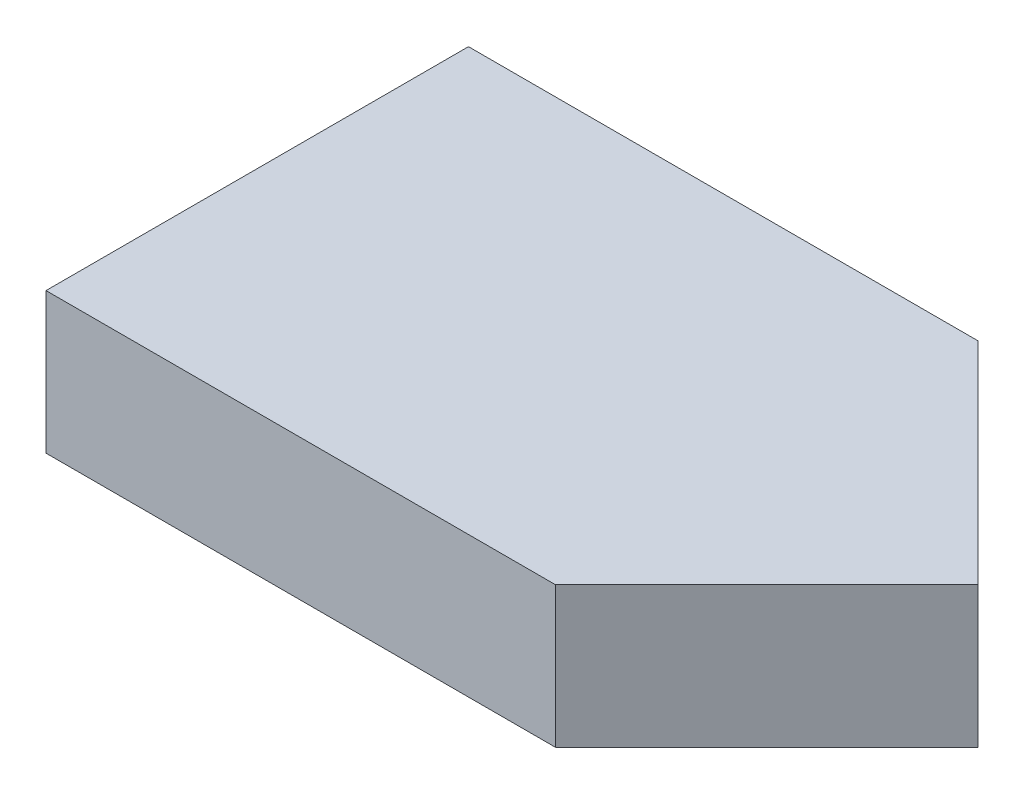
from build123d import *

# Parameters (mm, degrees)
SKETCH1_W           = 91.9
SKETCH1_H           = 38.1
BOSS_EXTRUDE1_DEPTH = 25.4


with BuildPart() as part:
    # Sketch1 → Boss-Extrude1 (new body)
    with BuildSketch(Plane(origin=(0, 0, 0), x_dir=(1, 0, 0), z_dir=(0, 1, 0))):
        with Locations((45.95, 19.05)):
            Rectangle(SKETCH1_W, SKETCH1_H)
        Polygon((91.9, 0), (130, 38.1), (91.9, 38.1), align=None)
        Polygon((130, 38.1), (91.9, 76.2), (91.9, 38.1), align=None)
        with Locations((45.95, 57.15)):
            Rectangle(SKETCH1_W, SKETCH1_H)
    extrude(amount=BOSS_EXTRUDE1_DEPTH)


solid = part.part
